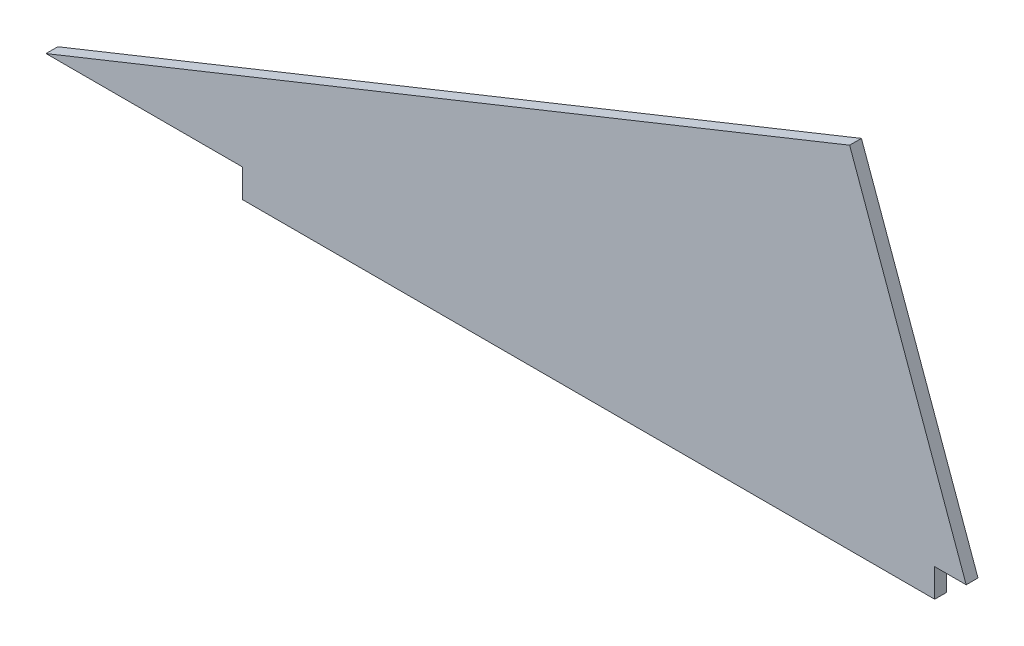
from build123d import *

# Parameters (mm, degrees)
BOSS_EXTRUDE1_DEPTH = 4.76


with BuildPart() as part:
    # Sketch2 → Boss-Extrude1 (new body)
    with BuildSketch(Plane.XY):
        Polygon((371, -20.340021117), (324, 109.659978883), (0, -20.340021117), (79.3, -20.340021117), (79.3, -31.740021117), (358.3, -31.740021117), (358.3, -20.340021117), align=None)
    extrude(amount=BOSS_EXTRUDE1_DEPTH)


solid = part.part
